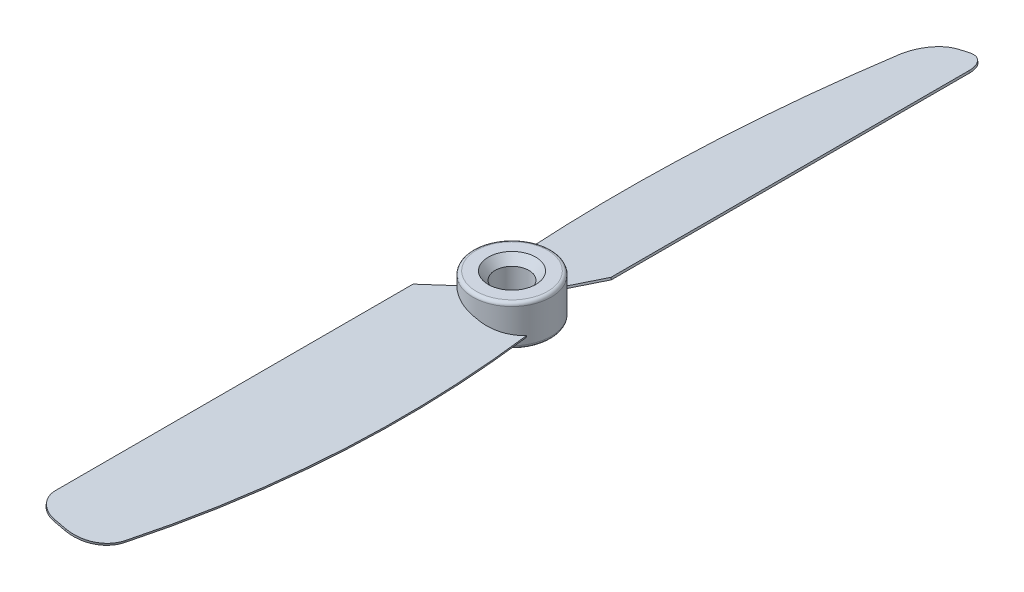
from build123d import *

# Parameters (mm, degrees)
SKETCH1_R             = 5.75
BOSS_EXTRUDE1_DEPTH   = 3
BOSS_EXTRUDE2_DEPTH   = 0.15
CIRPATTERN1_COUNT     = 2
SKETCH4_R             = 2.5
CUT_EXTRUDE1_DEPTH    = 7.0000001
FILLET1_R             = 0.5
CHAMFER1_SIZE         = 1
CHAMFER1_SIZE2        = 1.191753593
CHAMFER1_PART_2_SIZE  = 1
CHAMFER1_PART_2_SIZE2 = 1.191753593


with BuildPart() as part:
    # Sketch1 → Boss-Extrude1 (new body, symmetric)
    with BuildSketch(Plane(origin=(0, 0, 0), x_dir=(1, 0, 0), z_dir=(0, 1, 0))):
        Circle(SKETCH1_R)
    extrude(amount=BOSS_EXTRUDE1_DEPTH, both=True)

    # Sketch3 → Boss-Extrude2 (add, symmetric)
    with BuildSketch(Plane(origin=(0, 0, 0), x_dir=(0.974370065, -0.224951054, 0), z_dir=(-0.224951054, -0.974370065, 0))):
        with BuildLine():
            Line((-3.7810451, 3.485569564), (-7.073832927, 7.724962303))
            Line((-7.073832927, 7.724962303), (-7.073832927, 60.5))
            ThreePointArc((-7.073832927, 60.5), (-6.19515327, 62.621320344), (-4.073832927, 63.5))
            Line((-4.073832927, 63.5), (-2.360798549, 63.5))
            ThreePointArc((-2.360798549, 63.5), (0.785773005, 62.385754426), (2.529923187, 59.539634982))
            add(Edge.make_bspline(
                [(5.379401291, 3.122506591), (7.423883814, 22.153749757), (6.457878795, 41.061478518), (2.529923187, 59.539634982)],
                knots=[0, 0, 0, 0, 0.933242383, 0.933242383, 0.933242383, 0.933242383], degree=3))
            add(Edge.make_bspline(
                [(5.379401291, 3.122506591), (1.050826141, 9.991793378), (-3.7810451, 3.485569564)],
                knots=[5.286447688, 5.286447688, 5.286447688, 7.20272538, 7.20272538, 7.20272538], degree=2, weights=[1, 0.575043633, 1]))
        make_face()
    boss_extrude2 = extrude(amount=BOSS_EXTRUDE2_DEPTH, both=True)

    # CirPattern1: Boss-Extrude2 ×2 about axis
    cirpattern1_axis = Axis((0, 3, 0), (0, -1, 0))
    for i in range(1, CIRPATTERN1_COUNT):
        add(boss_extrude2.rotate(cirpattern1_axis, i * 360 / CIRPATTERN1_COUNT))

    # Sketch4 → Cut-Extrude1 (cut, through all)
    with BuildSketch(Plane(origin=(0, 3, 0), x_dir=(1, 0, 0), z_dir=(0, 1, 0))):
        Circle(SKETCH4_R)
    extrude(amount=-CUT_EXTRUDE1_DEPTH, mode=Mode.SUBTRACT)

    # Fillet1
    fillet1_edges = [part.edges().sort_by_distance(p)[0] for p in [
        (-5.75, -3, 0),
        (-5.75, 3, 0),
    ]]
    fillet(fillet1_edges, radius=FILLET1_R)

    # Chamfer1
    chamfer1_edges = [part.edges().sort_by_distance(p)[0] for p in [
        (-2.5, -3, 0),
    ]]
    chamfer1_side = [part.faces().sort_by_distance(p)[0] for p in [
        (-2.5, 0, 0),
    ]]
    chamfer(chamfer1_edges, length=CHAMFER1_SIZE, length2=CHAMFER1_SIZE2, reference=chamfer1_side[0])

    # Chamfer1 part 2
    chamfer1_part_2_edges = [part.edges().sort_by_distance(p)[0] for p in [
        (-2.5, 3, 0),
    ]]
    chamfer1_part_2_side = [part.faces().sort_by_distance(p)[0] for p in [
        (-5.101507576, 3, 0),
    ]]
    chamfer(chamfer1_part_2_edges, length=CHAMFER1_PART_2_SIZE, length2=CHAMFER1_PART_2_SIZE2, reference=chamfer1_part_2_side[0])


solid = part.part
